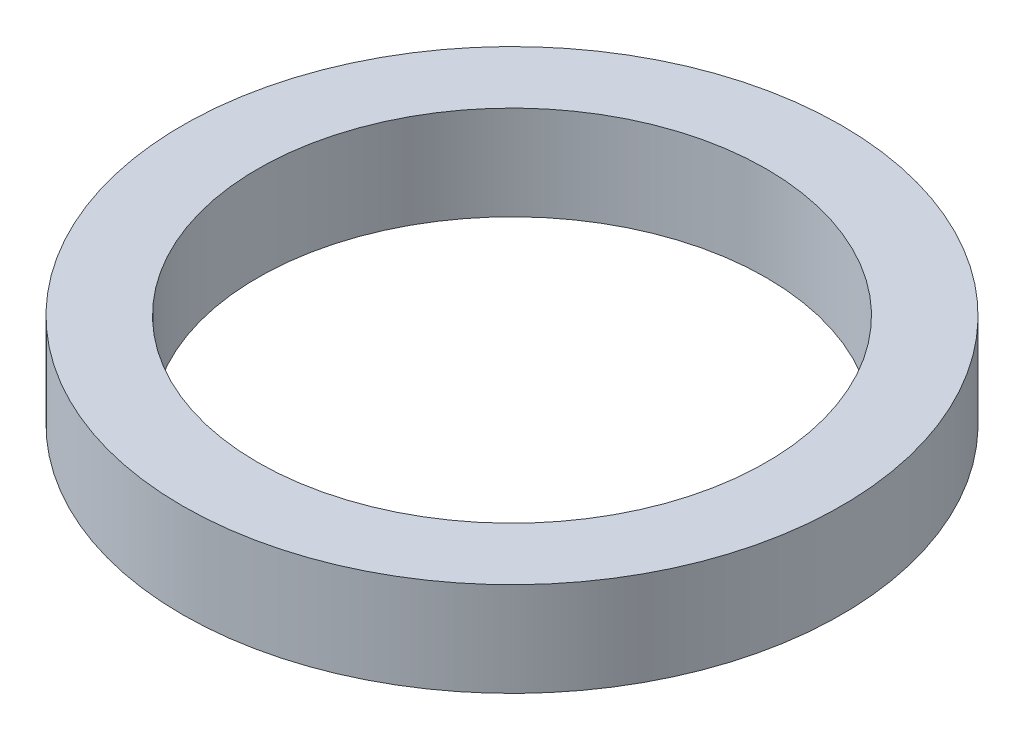
from build123d import *

# Parameters (mm, degrees)
SKETCH2_R           = 3.5
SKETCH2_R_2         = 2.7
BOSS_EXTRUDE1_DEPTH = 1


with BuildPart() as part:
    # Sketch2 → Boss-Extrude1 (new body)
    with BuildSketch(Plane(origin=(0, 0, 0), x_dir=(1, 0, 0), z_dir=(0, 1, 0))):
        Circle(SKETCH2_R)
        Circle(SKETCH2_R_2, mode=Mode.SUBTRACT)
    extrude(amount=BOSS_EXTRUDE1_DEPTH)


solid = part.part
